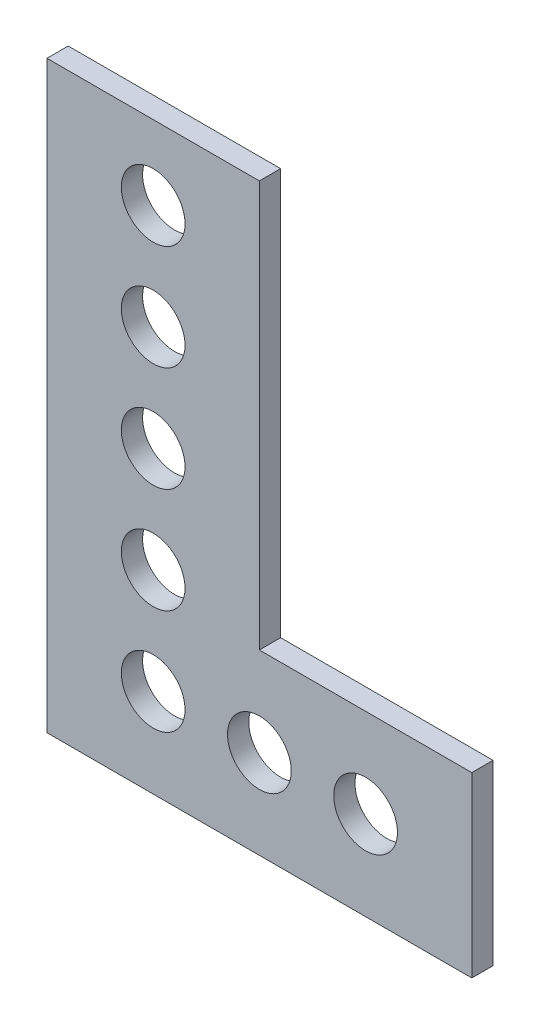
from build123d import *

# Parameters (mm, degrees)
SKETCH1_R           = 3
BOSS_EXTRUDE1_DEPTH = 2


with BuildPart() as part:
    # Sketch1 → Boss-Extrude1 (new body)
    with BuildSketch(Plane.XY):
        Polygon((-20, 55), (-20, 0), (20, 0), (20, 16.75), (0, 16.75), (0, 55), align=None)
        with Locations((-10, 48)):
            Circle(SKETCH1_R, mode=Mode.SUBTRACT)
        with Locations((10, 8.375)):
            Circle(SKETCH1_R, mode=Mode.SUBTRACT)
        with Locations((-10, 38.09375)):
            Circle(SKETCH1_R, mode=Mode.SUBTRACT)
        with Locations((-10, 28.1875)):
            Circle(SKETCH1_R, mode=Mode.SUBTRACT)
        with Locations((-10, 18.28125)):
            Circle(SKETCH1_R, mode=Mode.SUBTRACT)
        with Locations((-10, 8.375)):
            Circle(SKETCH1_R, mode=Mode.SUBTRACT)
        with Locations((0, 8.375)):
            Circle(SKETCH1_R, mode=Mode.SUBTRACT)
    extrude(amount=BOSS_EXTRUDE1_DEPTH)


solid = part.part
